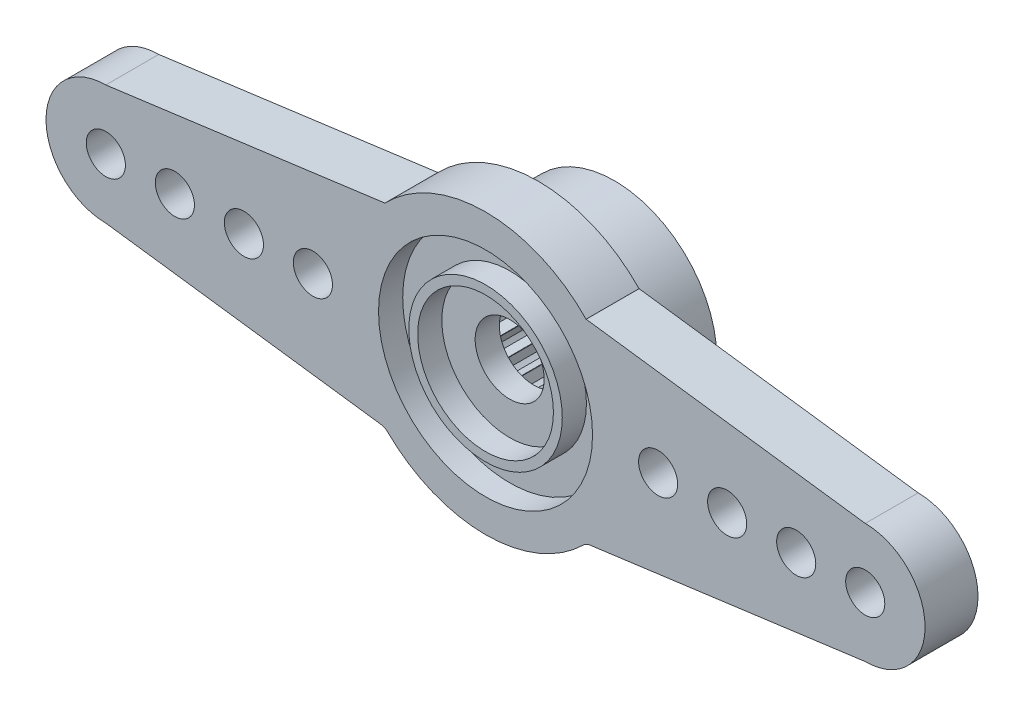
from build123d import *

# Parameters (mm, degrees)
IZIM1_R                     = 4.45
Y_KSEKLIK_EKSTR_ZYON1_DEPTH = 5.6
IZIM2_R                     = 0.85
IZIM2_R_2                   = 4.45
Y_KSEKLIK_EKSTR_ZYON3_DEPTH = 2.3
RADYUS1_R                   = 0.5
IZIM3_R                     = 2.95
KES_EKSTR_ZYON1_DEPTH       = 1.05
IZIM7_R                     = 4.65
IZIM7_R_2                   = 3.335
KES_EKSTR_ZYON3_DEPTH       = 1.05
IZIM8_R                     = 2.95
KES_EKSTR_ZYON5_DEPTH       = 1.05
IZIM9_R                     = 2.95
Y_KSEKLIK_EKSTR_ZYON4_DEPTH = 1.05
IZIM10_R                    = 1.5
KES_EKSTR_ZYON6_DEPTH       = 8.05
IZIM11_R                    = 2.68
KES_EKSTR_ZYON7_DEPTH       = 3.5
KES_EKSTR_ZYON10_DEPTH      = 12.5
DAIRESEL_KAPLAMA1_COUNT     = 24


with BuildPart() as part:
    # Çizim1 → Yükseklik-Ekstrüzyon1 (new body)
    with BuildSketch(Plane.XY):
        Circle(IZIM1_R)
    extrude(amount=Y_KSEKLIK_EKSTR_ZYON1_DEPTH)

    # Çizim2 → Yükseklik-Ekstrüzyon3 (add)
    with BuildSketch(Plane.XY.offset(5.6)):
        with BuildLine():
            Line((-4.370037185, 4.22), (-4.370301647, 4.22))
            Line((-4.370301647, 4.22), (-16.5, 2.6))
            ThreePointArc((-16.5, 2.6), (-19.1, 0), (-16.5, -2.6))
            Line((-16.5, -2.6), (-4.369998027, -4.22004055))
            ThreePointArc((-4.369998027, -4.22004055), (0, -6.075), (4.369998027, -4.22004055))
            Line((4.369998027, -4.22004055), (16.5, -2.6))
            ThreePointArc((16.5, -2.6), (19.1, 0), (16.5, 2.6))
            Line((16.5, 2.6), (4.370301647, 4.22))
            Line((4.370301647, 4.22), (4.370037185, 4.22))
            ThreePointArc((4.370037185, 4.22), (0, 6.075), (-4.370037185, 4.22))
        make_face()
        with Locations((-16.5, 0)):
            Circle(IZIM2_R, mode=Mode.SUBTRACT)
        with Locations((-13.5, 0)):
            Circle(IZIM2_R, mode=Mode.SUBTRACT)
        with Locations((-10.5, 0)):
            Circle(IZIM2_R, mode=Mode.SUBTRACT)
        with Locations((-7.5, 0)):
            Circle(IZIM2_R, mode=Mode.SUBTRACT)
        Circle(IZIM2_R_2, mode=Mode.SUBTRACT)
        with Locations((7.5, 0)):
            Circle(IZIM2_R, mode=Mode.SUBTRACT)
        with Locations((10.5, 0)):
            Circle(IZIM2_R, mode=Mode.SUBTRACT)
        with Locations((13.5, 0)):
            Circle(IZIM2_R, mode=Mode.SUBTRACT)
        with Locations((16.5, 0)):
            Circle(IZIM2_R, mode=Mode.SUBTRACT)
    extrude(amount=-Y_KSEKLIK_EKSTR_ZYON3_DEPTH)

    # Radyus1
    radyus1_edges = [part.edges().sort_by_distance(p)[0] for p in [
        (-4.369998027, -4.22004055, 4.45),
        (4.369998027, -4.22004055, 4.45),
    ]]
    fillet(radyus1_edges, radius=RADYUS1_R)

    # Çizim3 → Kes-Ekstrüzyon1 (cut)
    with BuildSketch(Plane(origin=(0, 0, 0), x_dir=(-1, 0, 0), z_dir=(0, 0, -1))):
        Circle(IZIM3_R)
    extrude(amount=-KES_EKSTR_ZYON1_DEPTH, mode=Mode.SUBTRACT)

    # Çizim7 → Kes-Ekstrüzyon3 (cut)
    with BuildSketch(Plane.XY.offset(5.6)):
        Circle(IZIM7_R)
        Circle(IZIM7_R_2, mode=Mode.SUBTRACT)
    extrude(amount=-KES_EKSTR_ZYON3_DEPTH, mode=Mode.SUBTRACT)

    # Çizim8 → Kes-Ekstrüzyon5 (cut)
    with BuildSketch(Plane.XY.offset(5.6)):
        with Locations(Location((0, 0, 0), (0, 0, 180))):
            Circle(IZIM8_R)
    extrude(amount=-KES_EKSTR_ZYON5_DEPTH, mode=Mode.SUBTRACT)

    # Çizim9 → Yükseklik-Ekstrüzyon4 (add)
    with BuildSketch(Plane(origin=(0, 0, 1.05), x_dir=(-1, 0, 0), z_dir=(0, 0, -1))):
        with Locations(Location((0, 0, 0), (0, 0, 180))):
            Circle(IZIM9_R)
    extrude(amount=Y_KSEKLIK_EKSTR_ZYON4_DEPTH)

    # Çizim10 → Kes-Ekstrüzyon6 (cut)
    with BuildSketch(Plane.XY.offset(4.55)):
        Circle(IZIM10_R)
    extrude(amount=-KES_EKSTR_ZYON6_DEPTH, mode=Mode.SUBTRACT)

    # Çizim11 → Kes-Ekstrüzyon7 (cut)
    with BuildSketch(Plane(origin=(0, 0, 0), x_dir=(-1, 0, 0), z_dir=(0, 0, -1))):
        Circle(IZIM11_R)
    extrude(amount=-KES_EKSTR_ZYON7_DEPTH, mode=Mode.SUBTRACT)

    # Çizim12 → Kes-Ekstrüzyon10 (cut)
    with BuildSketch(Plane(origin=(0, 0, 3.5), x_dir=(-1, 0, 0), z_dir=(0, 0, -1))):
        with BuildLine():
            Line((-2.000304803, 2.302451019), (-1.938517615, 1.850553824))
            ThreePointArc((-1.938517615, 1.850553824), (-1.686954029, 2.082447143), (-1.407896467, 2.280400741))
            Line((-1.407896467, 2.280400741), (-1.837127974, 2.434637716))
            ThreePointArc((-1.837127974, 2.434637716), (-1.919854398, 2.369949174), (-2.000304803, 2.302451019))
        make_face()
    kes_ekstr_zyon10 = extrude(amount=KES_EKSTR_ZYON10_DEPTH, mode=Mode.SUBTRACT)

    # Dairesel Kaplama1: Kes-Ekstrüzyon10 ×24 about axis
    dairesel_kaplama1_axis = Axis((0, 0, 0), (0, 0, 1))
    for i in range(1, DAIRESEL_KAPLAMA1_COUNT):
        add(kes_ekstr_zyon10.rotate(dairesel_kaplama1_axis, i * 360 / DAIRESEL_KAPLAMA1_COUNT), mode=Mode.SUBTRACT)


solid = part.part
